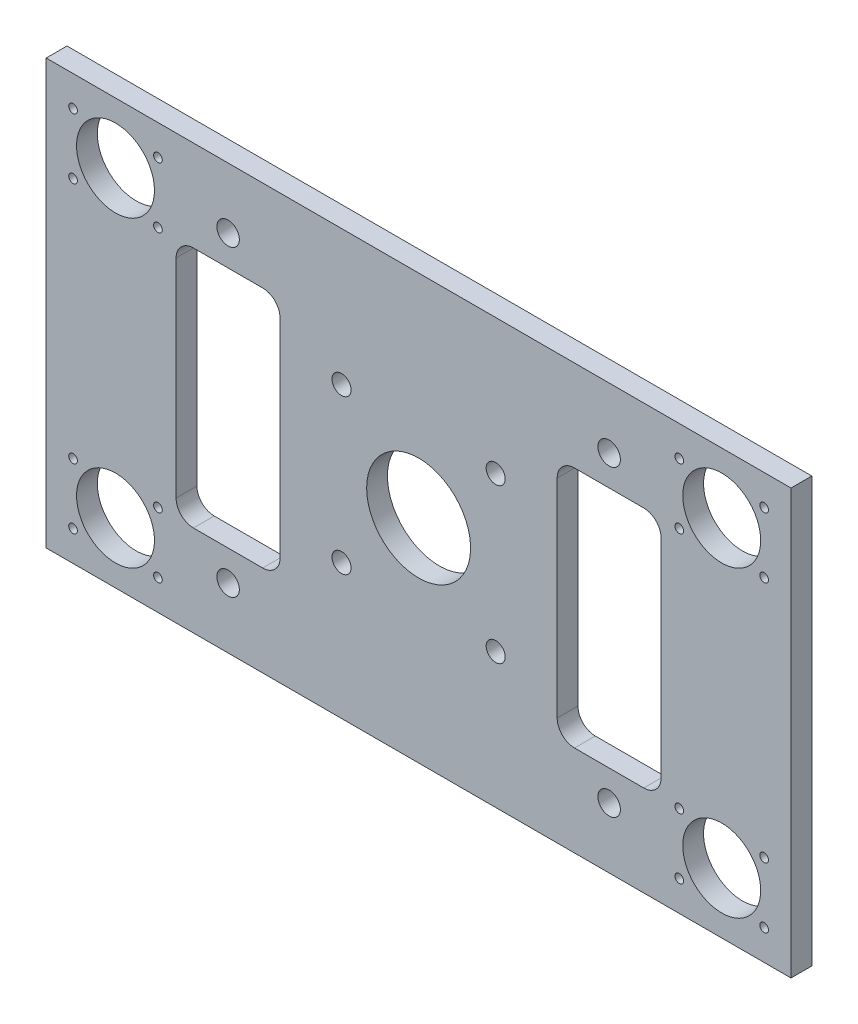
from build123d import *

# Parameters (mm, degrees)
SKETCH_1_W              = 430
SKETCH_1_H              = 245
EXTRUDE_1_DEPTH         = 6
SKETCH_2_R              = 22.5
CUT_EXTRUDE_1_DEPTH     = 13
HOLE_WIZARD_M6_1_D      = 5
CUT_EXTRUDE_2_DEPTH     = 13
HOLE_WIZARD_13_0_13_1_D = 13
CUT_EXTRUDE_3_DEPTH     = 13
EXTRUDE_2_DEPTH         = 12
FILLET_1_R              = 10
SKETCH_11_R             = 30
CUT_EXTRUDE_4_DEPTH     = 13
HOLE_WIZARD_11_0_11_1_D = 11


with BuildPart() as part:
    # 草图1 → 凸台-拉伸1 (new body, symmetric)
    with BuildSketch(Plane.XY):
        Rectangle(SKETCH_1_W, SKETCH_1_H)
    extrude(amount=EXTRUDE_1_DEPTH, both=True)

    # 草图2 → 切除-拉伸1 (cut, through all)
    with BuildSketch(Plane.XY.offset(6)):
        with Locations((-175, 87.5)):
            Circle(SKETCH_2_R)
        with Locations((175, 87.5)):
            Circle(SKETCH_2_R)
        with Locations((175, -87.5)):
            Circle(SKETCH_2_R)
        with Locations((-175, -87.5)):
            Circle(SKETCH_2_R)
    extrude(amount=-CUT_EXTRUDE_1_DEPTH, mode=Mode.SUBTRACT)

    # M6 螺纹孔1 (through all)
    with Locations(Plane.XY.offset(6)):
        with Locations((-199.5, 105), (-150.5, 105), (-150.5, 70), (-199.5, 70), (199.5, 70), (150.5, 70), (150.5, 105), (199.5, 105), (199.5, -105), (150.5, -105), (150.5, -70), (199.5, -70), (-199.5, -70), (-150.5, -70), (-150.5, -105), (-199.5, -105)):
            Hole(HOLE_WIZARD_M6_1_D / 2)

    # 草图5 → 切除-拉伸2 (cut, through all)
    with BuildSketch(Plane.XY.offset(6)):
        with BuildLine():
            Line((-130, -70), (130, -70))
            ThreePointArc((130, -70), (137.071067812, -67.071067812), (140, -60))
            Line((140, -60), (140, 60))
            ThreePointArc((140, 60), (137.071067812, 67.071067812), (130, 70))
            Line((130, 70), (-130, 70))
            ThreePointArc((-130, 70), (-137.071067812, 67.071067812), (-140, 60))
            Line((-140, 60), (-140, -60))
            ThreePointArc((-140, -60), (-137.071067812, -67.071067812), (-130, -70))
        make_face()
    extrude(amount=-CUT_EXTRUDE_2_DEPTH, mode=Mode.SUBTRACT)

    # Ø13.0 (13) 直径孔1 (through all)
    with Locations(Plane(origin=(0, 0, -6), x_dir=(-1, 0, 0), z_dir=(0, 0, -1))):
        with Locations((-110, 87.5), (110, 87.5), (110, -87.5), (-110, -87.5)):
            Hole(HOLE_WIZARD_13_0_13_1_D / 2)

    # 草图8 → 切除-拉伸3 (cut, through all)
    with BuildSketch(Plane(origin=(0, 0, -6), x_dir=(-1, 0, 0), z_dir=(0, 0, -1))):
        with BuildLine():
            Line((-80, 70), (80, 70))
            Line((80, 70), (80, 95))
            ThreePointArc((80, 95), (77.071067812, 102.071067812), (70, 105))
            Line((70, 105), (-70, 105))
            ThreePointArc((-70, 105), (-77.071067812, 102.071067812), (-80, 95))
            Line((-80, 95), (-80, 70))
        make_face()
        with BuildLine():
            Line((80, -70), (80, -95))
            ThreePointArc((80, -95), (77.071067812, -102.071067812), (70, -105))
            Line((70, -105), (-70, -105))
            ThreePointArc((-70, -105), (-77.071067812, -102.071067812), (-80, -95))
            Line((-80, -95), (-80, -70))
            Line((-80, -70), (80, -70))
        make_face()
    extrude(amount=-CUT_EXTRUDE_3_DEPTH, mode=Mode.SUBTRACT)

    # 草图10 → 凸台-拉伸2 (add)
    with BuildSketch(Plane(origin=(0, 0, -6), x_dir=(-1, 0, 0), z_dir=(0, 0, -1))):
        with BuildLine():
            Line((-80, -70), (-80, -95))
            ThreePointArc((-80, -95), (-77.071067812, -102.071067812), (-70, -105))
            Line((-70, -105), (70, -105))
            ThreePointArc((70, -105), (77.071067812, -102.071067812), (80, -95))
            Line((80, -95), (80, -70))
            Line((80, -70), (80, 70))
            Line((80, 70), (80, 95))
            ThreePointArc((80, 95), (77.071067812, 102.071067812), (70, 105))
            Line((70, 105), (-70, 105))
            ThreePointArc((-70, 105), (-77.071067812, 102.071067812), (-80, 95))
            Line((-80, 95), (-80, 70))
            Line((-80, 70), (-80, -70))
        make_face()
    extrude(amount=-EXTRUDE_2_DEPTH)

    # 圆角1
    fillet_1_edges = [part.edges().sort_by_distance(p)[0] for p in [
        (80, 70, 0),
        (-80, 70, 0),
        (80, -70, 0),
        (-80, -70, 0),
    ]]
    fillet(fillet_1_edges, radius=FILLET_1_R)

    # 草图11 → 切除-拉伸4 (cut, through all)
    with BuildSketch(Plane(origin=(0, 0, -6), x_dir=(-1, 0, 0), z_dir=(0, 0, -1))):
        Circle(SKETCH_11_R)
    extrude(amount=-CUT_EXTRUDE_4_DEPTH, mode=Mode.SUBTRACT)

    # Ø11.0 (11) 直径孔1 (through all)
    with Locations(Plane(origin=(44.5, 44.5, -6), x_dir=(-1, 0, 0), z_dir=(0, 0, -1))):
        with Locations((0, 0), (89, 0), (89, -89), (0, -89)):
            Hole(HOLE_WIZARD_11_0_11_1_D / 2)


solid = part.part
